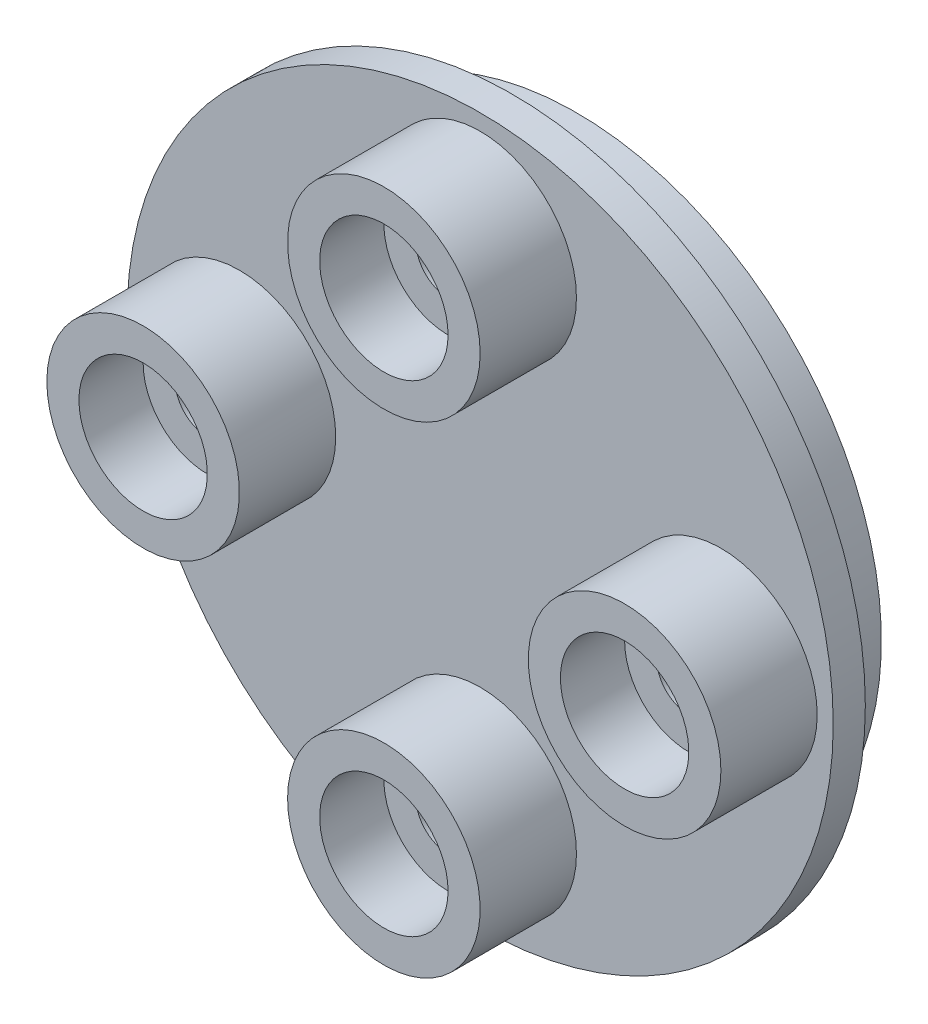
from build123d import *

# Parameters (mm, degrees)
SKETCH1_R                 = 3
BOSS_EXTRUDE3_DEPTH       = 4
BOSS_EXTRUDE3_2_DEPTH     = 4
BOSS_EXTRUDE3_3_DEPTH     = 4
BOSS_EXTRUDE3_4_DEPTH     = 4
SKETCH1_6_R               = 11
SKETCH1_6_R_2             = 3
BOSS_EXTRUDE9_DEPTH       = 1
SKETCH5_R                 = 2
CUT_EXTRUDE5_DEPTH        = 2
BOSS_EXTRUDE17_DEPTH      = 2
BOSS_EXTRUDE17_DEPTH_BACK = 0.0001
SKETCH9_R                 = 9.5
CUT_EXTRUDE11_START       = -0.5
SKETCH24_R                = 9
CUT_EXTRUDE11_DEPTH       = 1
FILLET10_R                = 1
SKETCH11_R                = 1
CUT_EXTRUDE13_DEPTH       = 2.5
CUT_EXTRUDE14_START       = -1
SKETCH26_R                = 1
CUT_EXTRUDE14_DEPTH       = 18.673332001
FILLET11_R                = 1


with BuildPart() as part:
    # Sketch1 → Boss-Extrude3 (new body)
    with BuildSketch(Plane.XY):
        with Locations((0, 7.5)):
            Circle(SKETCH1_R)
    extrude(amount=BOSS_EXTRUDE3_DEPTH)



with BuildPart() as body_2:
    # Sketch1 → Boss-Extrude3 2 (new body)
    with BuildSketch(Plane.XY):
        with Locations((0, -7.5)):
            Circle(SKETCH1_R)
    extrude(amount=BOSS_EXTRUDE3_2_DEPTH)


with BuildPart() as body_3:
    # Sketch1 → Boss-Extrude3 3 (new body)
    with BuildSketch(Plane.XY):
        with Locations((-7.5, 0)):
            Circle(SKETCH1_R)
    extrude(amount=BOSS_EXTRUDE3_3_DEPTH)


with BuildPart() as body_4:
    # Sketch1 → Boss-Extrude3 4 (new body)
    with BuildSketch(Plane.XY):
        with Locations((7.5, 0)):
            Circle(SKETCH1_R)
    extrude(amount=BOSS_EXTRUDE3_4_DEPTH)


with BuildPart() as part_1:
    add(part.part)

    add(body_2.part)  # Boss-Extrude9 merges body 2

    add(body_3.part)  # Boss-Extrude9 merges body 3

    add(body_4.part)  # Boss-Extrude9 merges body 4
    # Sketch1_6 → Boss-Extrude9 (add)
    with BuildSketch(Plane.XY):
        Circle(SKETCH1_6_R)
        with Locations((0, 7.5)):
            Circle(SKETCH1_6_R_2, mode=Mode.SUBTRACT)
        with Locations((-7.5, 0)):
            Circle(SKETCH1_6_R_2, mode=Mode.SUBTRACT)
        with Locations((0, -7.5)):
            Circle(SKETCH1_6_R_2, mode=Mode.SUBTRACT)
        with Locations((7.5, 0)):
            Circle(SKETCH1_6_R_2, mode=Mode.SUBTRACT)
    extrude(amount=BOSS_EXTRUDE9_DEPTH)

    # Sketch5 → Cut-Extrude5 (cut)
    with BuildSketch(Plane.XY.offset(4)):
        with Locations((0, 7.5)):
            Circle(SKETCH5_R)
        with Locations((7.5, 0)):
            Circle(SKETCH5_R)
        with Locations((0, -7.5)):
            Circle(SKETCH5_R)
        with Locations((-7.5, 0)):
            Circle(SKETCH5_R)
    extrude(amount=-CUT_EXTRUDE5_DEPTH, mode=Mode.SUBTRACT)

    # Sketch9 → Boss-Extrude17 (add, two sides: drawn at the far end of the back side and taken through both)
    with BuildSketch(Plane(origin=(0, 0, 0), x_dir=(-1, 0, 0), z_dir=(0, 0, -1)).offset(-BOSS_EXTRUDE17_DEPTH_BACK)):
        Circle(SKETCH9_R)
    extrude(amount=BOSS_EXTRUDE17_DEPTH + BOSS_EXTRUDE17_DEPTH_BACK)

    # Sketch24 → Cut-Extrude11 (cut)
    with BuildSketch(Plane(origin=(0, 0, -2), x_dir=(-1, 0, 0), z_dir=(0, 0, -1)).offset(CUT_EXTRUDE11_START)):
        Circle(SKETCH24_R)
    extrude(amount=-CUT_EXTRUDE11_DEPTH, mode=Mode.SUBTRACT)

    # Fillet10
    fillet10_edges = [part_1.edges().sort_by_distance(p)[0] for p in [
        (9.5, 0, 0),
    ]]
    fillet(fillet10_edges, radius=FILLET10_R)

    # Sketch11 → Cut-Extrude13 (cut)
    with BuildSketch(Plane.XY.offset(2)):
        with Locations((0, 7.5)):
            Circle(SKETCH11_R)
        with Locations((-7.5, 0)):
            Circle(SKETCH11_R)
        with Locations((0, -7.5)):
            Circle(SKETCH11_R)
        with Locations((7.5, 0)):
            Circle(SKETCH11_R)
    extrude(amount=-CUT_EXTRUDE13_DEPTH, mode=Mode.SUBTRACT)

    # Sketch29 → Revolve3 (revolve)
    with BuildSketch(Plane(origin=(0, 0, 0), x_dir=(0, 0, -1), z_dir=(1, 0, 0))):
        Polygon((2, 0), (2, 2), (5.5, 1.5), (5.5, 0), align=None)
    revolve(axis=Axis((0, 0, -2), (0, 0, -1)))

    # Sketch26 → Cut-Extrude14 (cut, through all)
    with BuildSketch(Plane(origin=(0, 0, -2), x_dir=(-1, 0, 0), z_dir=(0, 0, -1)).offset(CUT_EXTRUDE14_START)):
        Circle(SKETCH26_R)
    extrude(amount=CUT_EXTRUDE14_DEPTH, mode=Mode.SUBTRACT)

    # Fillet11
    fillet11_edges = [part_1.edges().sort_by_distance(p)[0] for p in [
        (0, -2, -2),
    ]]
    fillet(fillet11_edges, radius=FILLET11_R)


solid = part_1.part
